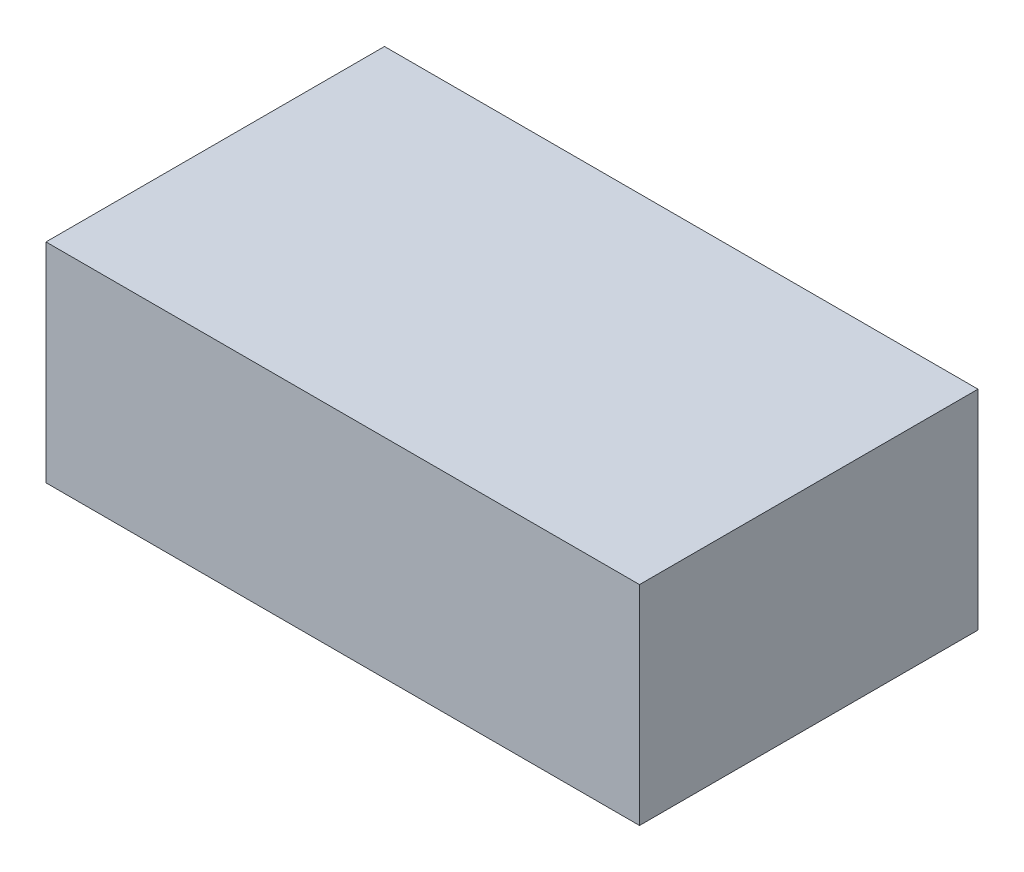
from build123d import *

# Parameters (mm, degrees)
SKETCH6_W           = 128
SKETCH6_H           = 73
BOSS_EXTRUDE1_DEPTH = 4
SKETCH7_W           = 128
SKETCH7_H           = 73
SKETCH7_W_2         = 120
SKETCH7_H_2         = 65
BOSS_EXTRUDE2_DEPTH = 41
BOSS_EXTRUDE4_DEPTH = 34
CUT_EXTRUDE1_REACH  = 75
SKETCH10_R          = 10.16
CUT_EXTRUDE2_REACH  = 130


with BuildPart() as part:
    # Sketch6 → Boss-Extrude1 (new body)
    with BuildSketch(Plane(origin=(0, 0, 0), x_dir=(1, 0, 0), z_dir=(0, 1, 0))):
        Rectangle(SKETCH6_W, SKETCH6_H)
    extrude(amount=-BOSS_EXTRUDE1_DEPTH)

    # Sketch7 → Boss-Extrude2 (add)
    with BuildSketch(Plane.XZ.offset(4)):
        Rectangle(SKETCH7_W, SKETCH7_H)
        Rectangle(SKETCH7_W_2, SKETCH7_H_2, mode=Mode.SUBTRACT)
    extrude(amount=BOSS_EXTRUDE2_DEPTH)

    # Sketch9 → Boss-Extrude4 (add)
    with BuildSketch(Plane.XZ.offset(4)):
        Polygon((-5, 32.5), (-5, -32.5), (-18.5, -32.5), (-18.5, -21.3), (-15, -21.3), (-15, -26.3), (-11, -26.3), (-11, 26.3), (-15, 26.3), (-15, 21.3), (-18.5, 21.3), (-18.5, 32.5), align=None)
    extrude(amount=BOSS_EXTRUDE4_DEPTH)

    # Sketch10 → Cut-Extrude1 (cut, up to next)
    with BuildSketch(Plane(origin=(0, 0, -36.5), x_dir=(-1, 0, 0), z_dir=(0, 0, -1)), mode=Mode.PRIVATE) as cut_extrude1_sk1:
        with Locations((44, -25)):
            Circle(SKETCH10_R)
    cut_extrude1_tool1 = extrude(cut_extrude1_sk1.sketch, amount=-CUT_EXTRUDE1_REACH, mode=Mode.PRIVATE) & part.part
    add(cut_extrude1_tool1.solids().sort_by_distance((-44, -25, -36.5))[0], mode=Mode.SUBTRACT)

    # Sketch13 → Cut-Extrude2 (cut, up to next)
    with BuildSketch(Plane.ZY.offset(64), mode=Mode.PRIVATE) as cut_extrude2_sk1:
        with BuildLine():
            Line((-12, -21), (12, -21))
            ThreePointArc((12, -21), (16, -25), (12, -29))
            Line((12, -29), (-12, -29))
            ThreePointArc((-12, -29), (-16, -25), (-12, -21))
        make_face()
    cut_extrude2_tool1 = extrude(cut_extrude2_sk1.sketch, amount=-CUT_EXTRUDE2_REACH, mode=Mode.PRIVATE) & part.part
    add(cut_extrude2_tool1.solids().sort_by_distance((-64, -25, 0))[0], mode=Mode.SUBTRACT)


solid = part.part
